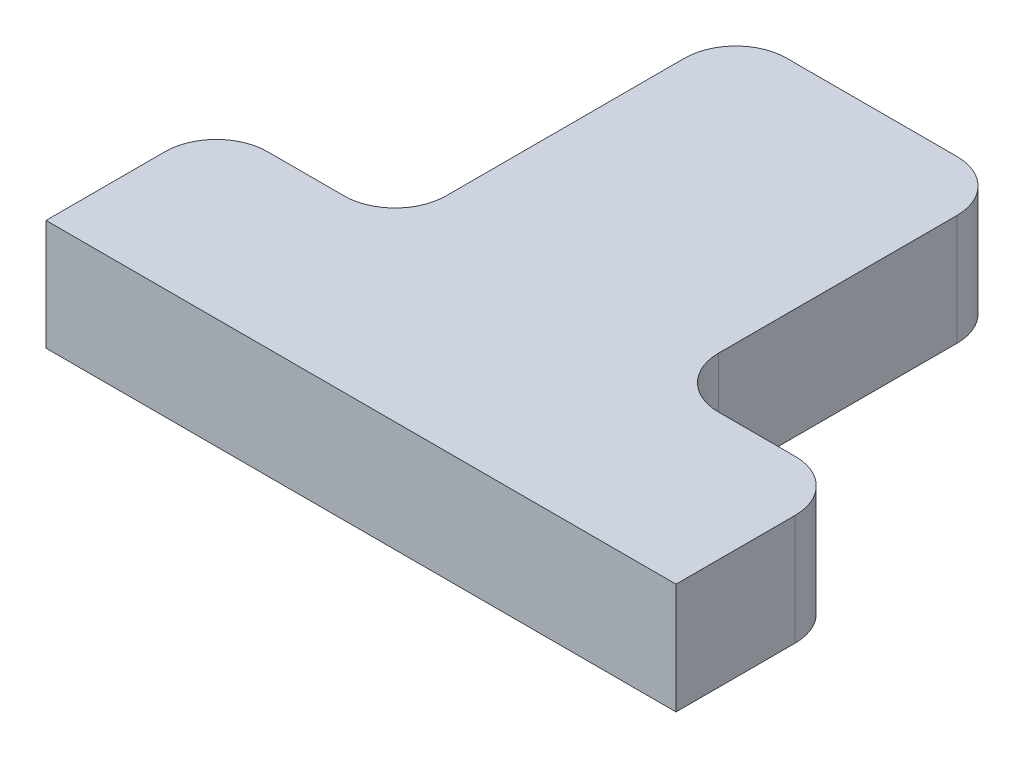
from build123d import *

# Parameters (mm, degrees)
BOSS_EXTRUDE1_DEPTH = 6.5
FILLET1_R           = 3


with BuildPart() as part:
    # Sketch1 → Boss-Extrude1 (new body)
    with BuildSketch(Plane(origin=(0, 0, 0), x_dir=(1, 0, 0), z_dir=(0, 1, 0))):
        Polygon((0, 0), (16, 0), (26.5, 0), (26.5, 10), (16, 10), (16, 30), (0, 30), (0, 10), (-10.5, 10), (-10.5, 0), align=None)
    extrude(amount=BOSS_EXTRUDE1_DEPTH)

    # Fillet1
    fillet1_edges = [part.edges().sort_by_distance(p)[0] for p in [
        (0, 3.25, -10),
        (0, 3.25, -30),
        (16, 3.25, -30),
        (16, 3.25, -10),
        (26.5, 3.25, -10),
        (-10.5, 3.25, -10),
    ]]
    fillet(fillet1_edges, radius=FILLET1_R)


solid = part.part
